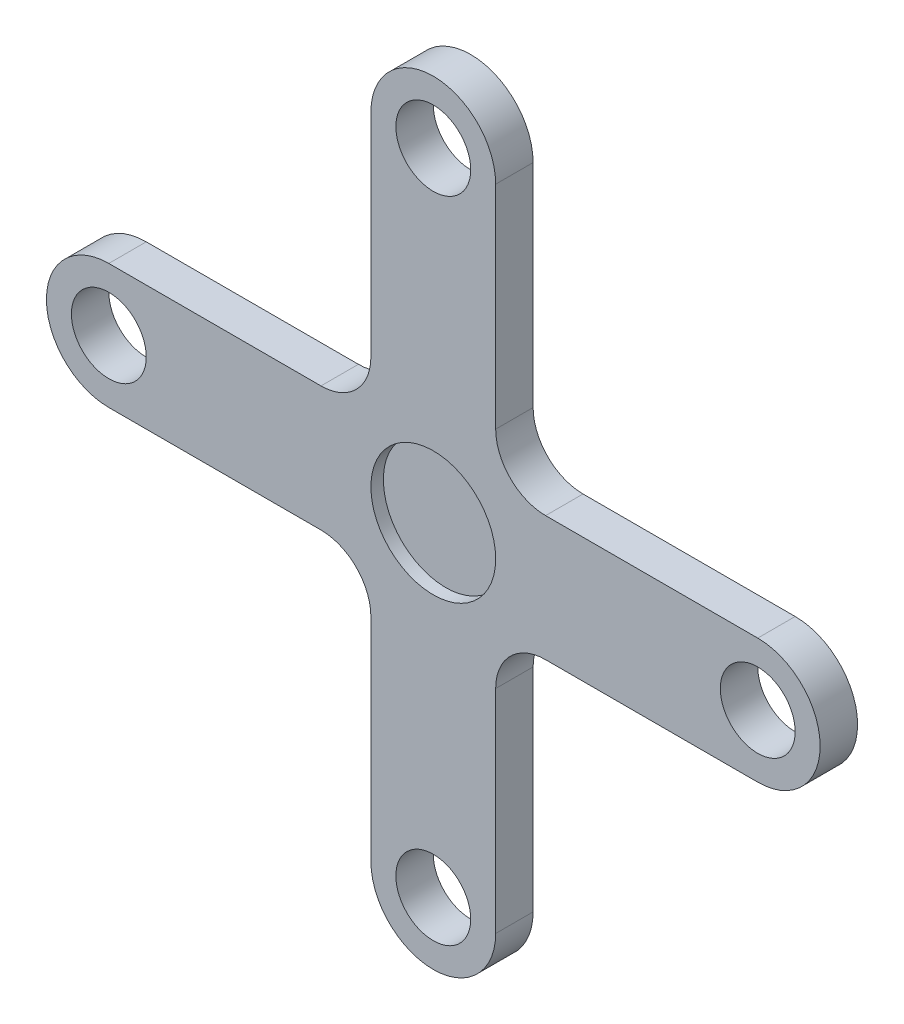
from build123d import *

# Parameters (mm, degrees)
IZIM1_R                     = 1.5
Y_KSEKLIK_EKSTR_ZYON1_DEPTH = 1.5
IZIM2_R                     = 2.5
KES_EKSTR_ZYON1_DEPTH       = 0.5


with BuildPart() as part:
    # Çizim1 → Yükseklik-Ekstrüzyon1 (new body)
    with BuildSketch(Plane.XY):
        with BuildLine():
            Line((-2.5, -13), (-2.5, -4.5))
            ThreePointArc((-2.5, -4.5), (-3.085786438, -3.085786438), (-4.5, -2.5))
            Line((-4.5, -2.5), (-13, -2.5))
            ThreePointArc((-13, -2.5), (-15.5, 0), (-13, 2.5))
            Line((-13, 2.5), (-4.5, 2.5))
            ThreePointArc((-4.5, 2.5), (-3.085786438, 3.085786438), (-2.5, 4.5))
            Line((-2.5, 4.5), (-2.5, 13))
            ThreePointArc((-2.5, 13), (0, 15.5), (2.5, 13))
            Line((2.5, 13), (2.5, 4.5))
            ThreePointArc((2.5, 4.5), (3.085786438, 3.085786438), (4.5, 2.5))
            Line((4.5, 2.5), (13, 2.5))
            ThreePointArc((13, 2.5), (15.5, 0), (13, -2.5))
            Line((13, -2.5), (4.5, -2.5))
            ThreePointArc((4.5, -2.5), (3.085786438, -3.085786438), (2.5, -4.5))
            Line((2.5, -4.5), (2.5, -13))
            ThreePointArc((2.5, -13), (0, -15.5), (-2.5, -13))
        make_face()
        with Locations((0, 13)):
            Circle(IZIM1_R, mode=Mode.SUBTRACT)
        with Locations((13, 0)):
            Circle(IZIM1_R, mode=Mode.SUBTRACT)
        with Locations((0, -13)):
            Circle(IZIM1_R, mode=Mode.SUBTRACT)
        with Locations((-13, 0)):
            Circle(IZIM1_R, mode=Mode.SUBTRACT)
    extrude(amount=Y_KSEKLIK_EKSTR_ZYON1_DEPTH)

    # Çizim2 → Kes-Ekstrüzyon1 (cut)
    with BuildSketch(Plane.XY.offset(1.5)):
        Circle(IZIM2_R)
    extrude(amount=-KES_EKSTR_ZYON1_DEPTH, mode=Mode.SUBTRACT)


solid = part.part
